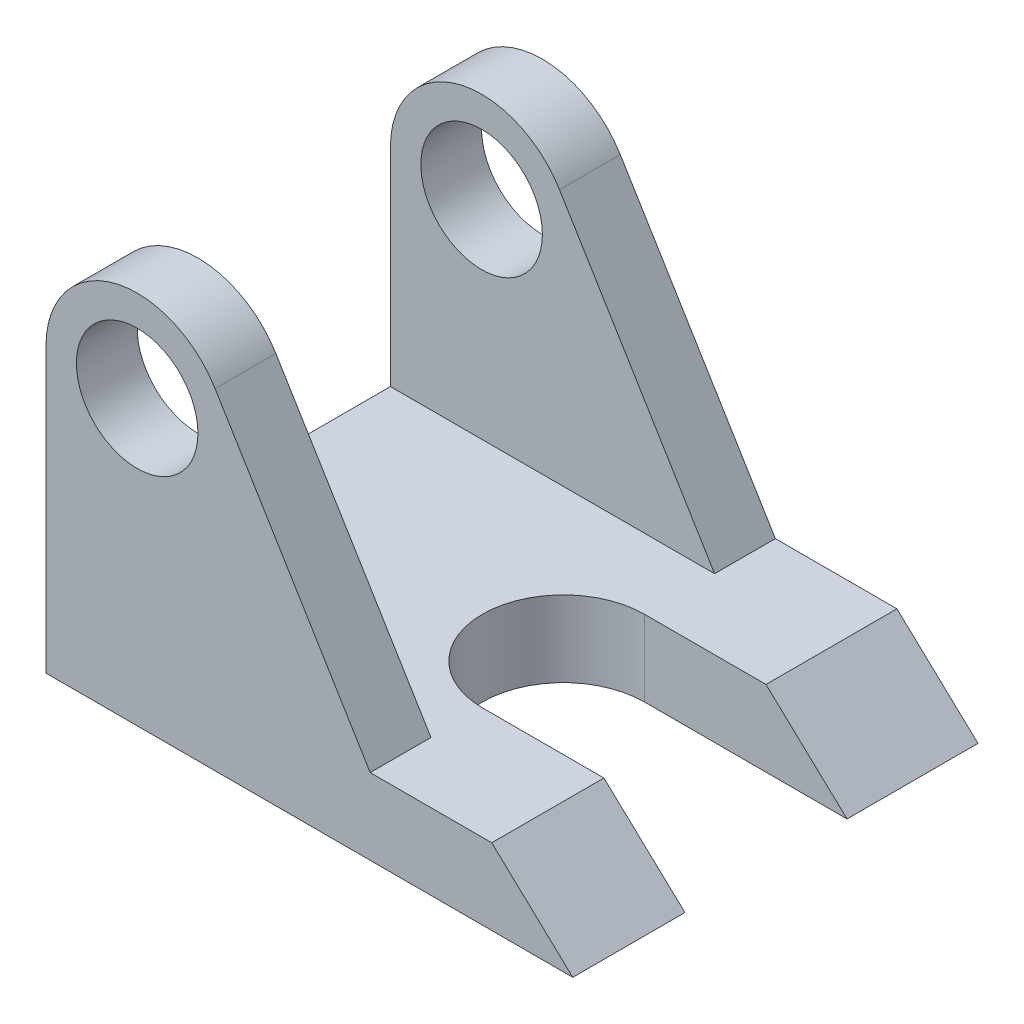
from build123d import *

# Parameters (mm, degrees)
SKETCH1_R           = 15
BOSS_EXTRUDE1_DEPTH = 100
SKETCH3_W           = 70
SKETCH3_H           = 73.742288546
CUT_EXTRUDE1_DEPTH  = 50
CUT_EXTRUDE2_DEPTH  = 20


with BuildPart() as part:
    # Sketch1 → Boss-Extrude1 (new body)
    with BuildSketch(Plane.XY):
        with BuildLine():
            Line((-49.633171283, 65.600501081), (-49.633171283, -4.399498919))
            Line((-49.633171283, -4.399498919), (80.366828717, -4.399498919))
            Line((80.366828717, -4.399498919), (60.366828717, 14.358212535))
            Line((60.366828717, 14.358212535), (30.366828717, 14.358212535))
            Line((30.366828717, 14.358212535), (-7.909440204, 77.292300062))
            ThreePointArc((-7.909440204, 77.292300062), (-33.204252353, 87.265956872), (-49.633171283, 65.600501081))
        make_face()
        with Locations((-27.133171283, 65.600501081)):
            Circle(SKETCH1_R, mode=Mode.SUBTRACT)
    extrude(amount=-BOSS_EXTRUDE1_DEPTH)

    # Sketch3 → Cut-Extrude1 (cut, symmetric)
    with BuildSketch(Plane(origin=(0, 0, 0), x_dir=(0, 0, -1), z_dir=(1, 0, 0))):
        with Locations((50, 51.229356808)):
            Rectangle(SKETCH3_W, SKETCH3_H)
    extrude(amount=CUT_EXTRUDE1_DEPTH, both=True, mode=Mode.SUBTRACT)

    # Sketch4 → Cut-Extrude2 (cut, symmetric)
    with BuildSketch(Plane(origin=(0, 14.358212535, 0), x_dir=(1, 0, 0), z_dir=(0, 1, 0))):
        with BuildLine():
            Line((30.366828717, 67.683852826), (82.708182872, 67.683852826))
            Line((82.708182872, 67.683852826), (82.708182872, 27.683852826))
            Line((82.708182872, 27.683852826), (30.366828717, 27.683852826))
            ThreePointArc((30.366828717, 27.683852826), (10.366828717, 47.683852826), (30.366828717, 67.683852826))
        make_face()
    extrude(amount=CUT_EXTRUDE2_DEPTH, both=True, mode=Mode.SUBTRACT)


solid = part.part
